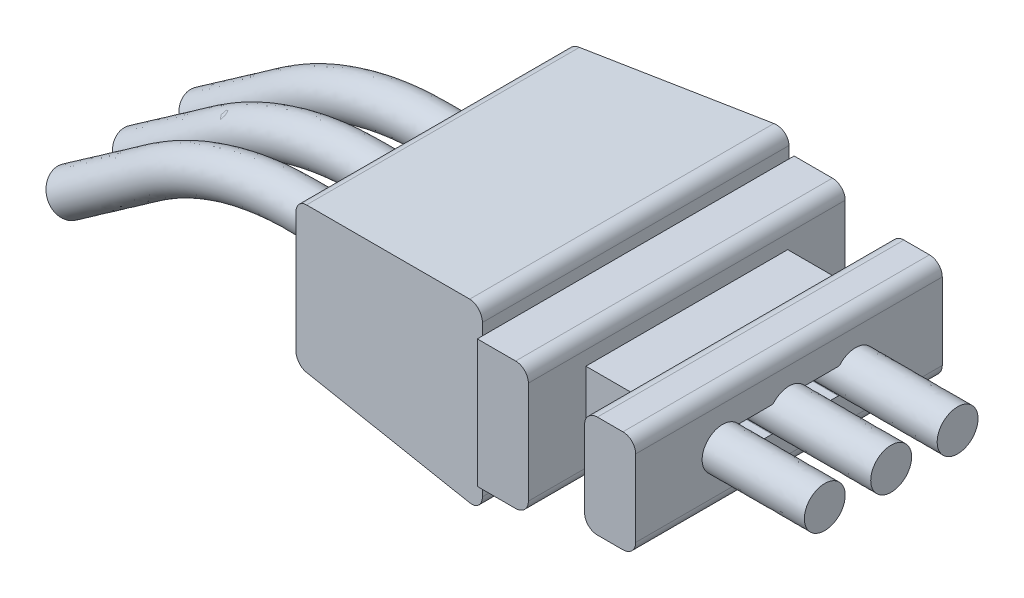
from build123d import *

# Parameters (mm, degrees)
SKETCH1_W            = 6
SKETCH1_H            = 2
BOSS_EXTRUDE1_DEPTH  = 1
SKETCH2_W            = 3.95
SKETCH2_H            = 1.45
BOSS_EXTRUDE2_DEPTH  = 1
SKETCH3_W            = 6.2
SKETCH3_H            = 2.5
BOSS_EXTRUDE3_DEPTH  = 1
SKETCH4_W            = 6
SKETCH4_H            = 3.5
BOSS_EXTRUDE4_DEPTH  = 4
BOSS_EXTRUDE4_TAPER  = 5
FILLET2_R            = 0.25
CUT_EXTRUDE6_DEPTH   = 8
SWEEP3_PROFILE_R     = 0.4
LPATTERN1_COUNT      = 2
LPATTERN1_PITCH      = 1.3
LPATTERN1_COUNT_DIR2 = 2
LPATTERN1_PITCH_DIR2 = 1.3


with BuildPart() as part:
    # Sketch1 → Boss-Extrude1 (new body)
    with BuildSketch(Plane(origin=(0, 0, 0), x_dir=(0, 0, -1), z_dir=(1, 0, 0))):
        Rectangle(SKETCH1_W, SKETCH1_H)
    extrude(amount=BOSS_EXTRUDE1_DEPTH)

    # Sketch2 → Boss-Extrude2 (add)
    with BuildSketch(Plane.ZY):
        Rectangle(SKETCH2_W, SKETCH2_H)
    extrude(amount=BOSS_EXTRUDE2_DEPTH)

    # Sketch3 → Boss-Extrude3 (add)
    with BuildSketch(Plane.ZY.offset(1)):
        Rectangle(SKETCH3_W, SKETCH3_H)
    extrude(amount=BOSS_EXTRUDE3_DEPTH)

    # Sketch4 → Boss-Extrude4 (add)
    with BuildSketch(Plane.ZY.offset(2)):
        Rectangle(SKETCH4_W, SKETCH4_H)
    extrude(amount=BOSS_EXTRUDE4_DEPTH, taper=BOSS_EXTRUDE4_TAPER)

    # Fillet2
    fillet2_edges = [part.edges().sort_by_distance(p)[0] for p in [
        (1, -1, 0),
        (-1, -1.25, 0),
        (-1, 1.25, 0),
        (-2, -1.75, 0),
        (-2, 1.75, 0),
        (-6, -1.400045346, 0),
        (-6, 1.400045346, 0),
        (0, -1, 0),
        (0, 1, 0),
        (1, 1, 0),
    ]]
    fillet(fillet2_edges, radius=FILLET2_R)

    # Sketch15 → Cut-Extrude6 (cut, through all)
    with BuildSketch(Plane.ZY.offset(6)):
        with BuildLine():
            Line((-0.964589803, 0.25), (-0.335410197, 0.25))
            ThreePointArc((-0.335410197, 0.25), (-0.314997782, 0.254356454), (-0.298142397, 0.266666667))
            ThreePointArc((-0.298142397, 0.266666667), (0, 0.4), (0.298142397, 0.266666667))
            ThreePointArc((0.298142397, 0.266666667), (0.314997782, 0.254356454), (0.335410197, 0.25))
            Line((0.335410197, 0.25), (0.964589803, 0.25))
            ThreePointArc((0.964589803, 0.25), (0.985002218, 0.254356454), (1.001857603, 0.266666667))
            ThreePointArc((1.001857603, 0.266666667), (1.7, 0), (1.001857603, -0.266666667))
            ThreePointArc((1.001857603, -0.266666667), (0.985002218, -0.254356454), (0.964589803, -0.25))
            Line((0.964589803, -0.25), (0.335410197, -0.25))
            ThreePointArc((0.335410197, -0.25), (0.314997782, -0.254356454), (0.298142397, -0.266666667))
            ThreePointArc((0.298142397, -0.266666667), (0, -0.4), (-0.298142397, -0.266666667))
            ThreePointArc((-0.298142397, -0.266666667), (-0.314997782, -0.254356454), (-0.335410197, -0.25))
            Line((-0.335410197, -0.25), (-0.964589803, -0.25))
            ThreePointArc((-0.964589803, -0.25), (-0.985002218, -0.254356454), (-1.001857603, -0.266666667))
            ThreePointArc((-1.001857603, -0.266666667), (-1.7, 0), (-1.001857603, 0.266666667))
            ThreePointArc((-1.001857603, 0.266666667), (-0.985002218, 0.254356454), (-0.964589803, 0.25))
        make_face()
    extrude(amount=-CUT_EXTRUDE6_DEPTH, mode=Mode.SUBTRACT)


with BuildPart() as body_2:
    # Sweep3: sweep along a path in Sketch10
    with BuildLine(Plane.XY) as sweep3_path:
        Line((-11.779692326, -2.051392651), (-10.141388237, -0.904239779))
        ThreePointArc((-10.141388237, -0.904239779), (-8.777035053, -0.231415246), (-7.273506056, 0))
        Line((-7.273506056, 0), (1, 0))
        Line((1, 0), (3, 0))
    # Sweep3 profile (on start of the path) → Sweep3 (sweep)
    with BuildSketch(Plane(origin=(-11.779692326, -2.051392651, 0), x_dir=(-0.573576436, 0.819152044, 0), z_dir=(0.819152044, 0.573576436, 0))):
        Circle(SWEEP3_PROFILE_R)
    sweep3 = sweep(path=sweep3_path.line)


with BuildPart() as lpattern1_1:
    # LPattern1: Sweep3 2 × 2
    with Locations(*[Vector(0, 0, 1) * (i * LPATTERN1_PITCH) + Vector(0, 0, -1) * (j * LPATTERN1_PITCH_DIR2) for i in range(LPATTERN1_COUNT) for j in range(LPATTERN1_COUNT_DIR2) if (i, j) != (0, 0)]):
        add(sweep3)


solid = Compound([part.part, body_2.part, lpattern1_1.part])
